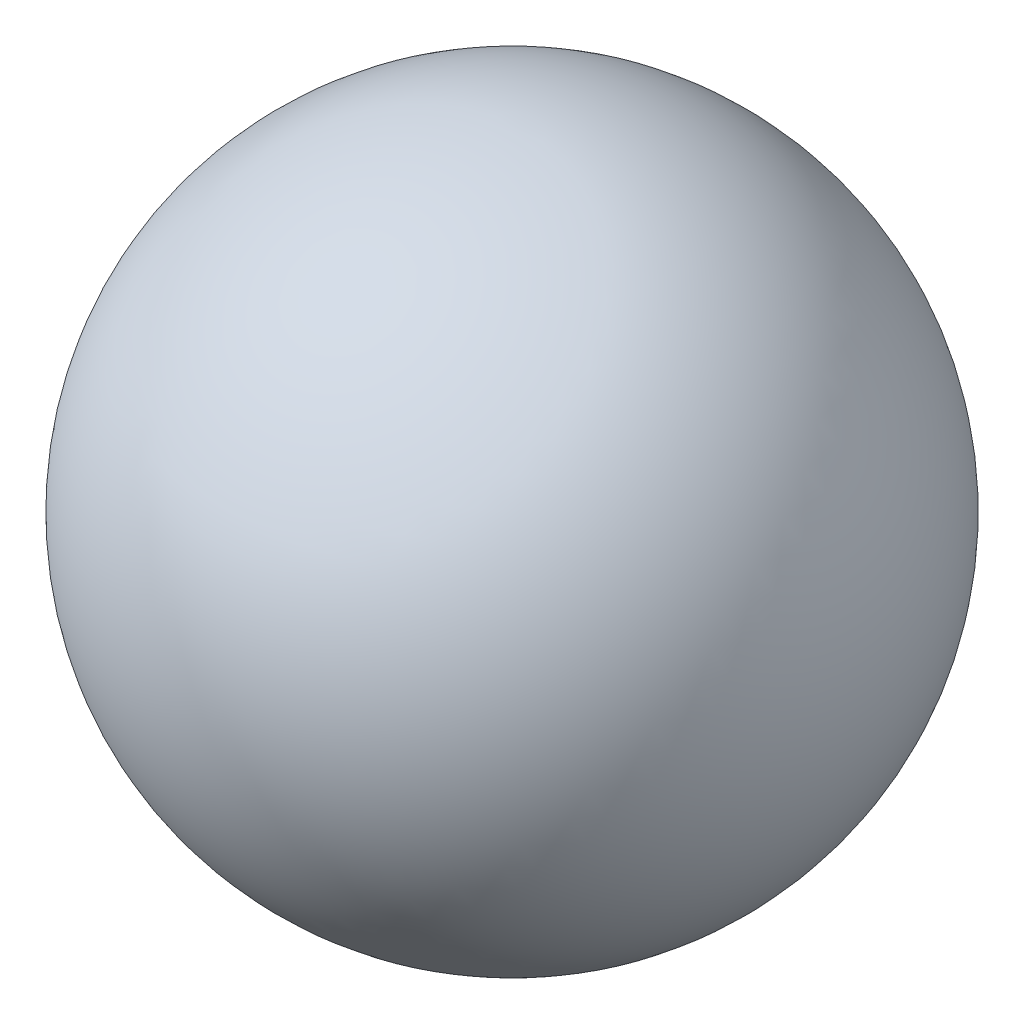
from build123d import *


with BuildPart() as part:
    # ｽｹｯﾁ1 → 回転2 (revolve)
    with BuildSketch(Plane.XY):
        with BuildLine():
            Line((0, 0.048895716), (0, -0.048895716))
            ThreePointArc((0, -0.048895716), (0.048895716, 0), (0, 0.048895716))
        make_face()
    revolve(axis=Axis((0, 0.048895716, 0), (0, -1, 0)))


solid = part.part
